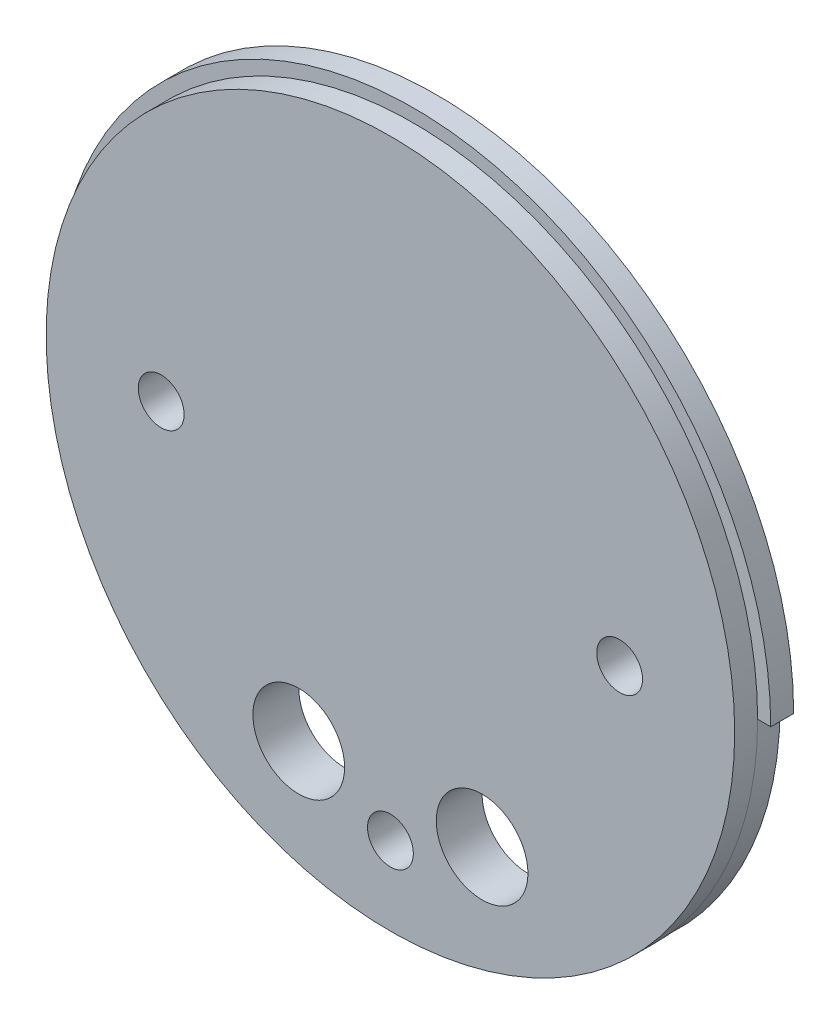
from build123d import *

# Parameters (mm, degrees)
SKETCH1_R           = 49.5046
BOSS_EXTRUDE1_DEPTH = 3.175
SKETCH2_R           = 47.6885
BOSS_EXTRUDE2_DEPTH = 3.175
SKETCH3_R           = 3.175
SKETCH3_R_2         = 6.35
CUT_EXTRUDE1_DEPTH  = 7.35
CUT_EXTRUDE2_DEPTH  = 4.175


with BuildPart() as part:
    # Sketch1 → Boss-Extrude1 (new body)
    with BuildSketch(Plane.XY):
        Circle(SKETCH1_R)
    extrude(amount=BOSS_EXTRUDE1_DEPTH)

    # Sketch2 → Boss-Extrude2 (add)
    with BuildSketch(Plane.XY.offset(3.175)):
        Circle(SKETCH2_R)
    extrude(amount=BOSS_EXTRUDE2_DEPTH)

    # Sketch3 → Cut-Extrude1 (cut, through all)
    with BuildSketch(Plane.XY.offset(6.35)):
        with Locations((-31.75, 0)):
            Circle(SKETCH3_R)
        with Locations((31.75, 0)):
            Circle(SKETCH3_R)
        with Locations((-12.7, -31.235352443)):
            Circle(SKETCH3_R_2)
        with Locations((12.7, -31.235352443)):
            Circle(SKETCH3_R_2)
        with Locations((0, -36.8046)):
            Circle(SKETCH3_R)
    extrude(amount=-CUT_EXTRUDE1_DEPTH, mode=Mode.SUBTRACT)

    # Sketch4 → Cut-Extrude2 (cut, through all)
    with BuildSketch(Plane.XY.offset(3.175)):
        with BuildLine():
            Line((-50.165, 0), (-47.625, 0))
            ThreePointArc((-47.625, 0), (0, -47.625), (47.625, 0))
            Line((47.625, 0), (50.165, 0))
            ThreePointArc((50.165, 0), (0, -50.165), (-50.165, 0))
        make_face()
    extrude(amount=-CUT_EXTRUDE2_DEPTH, mode=Mode.SUBTRACT)


solid = part.part
